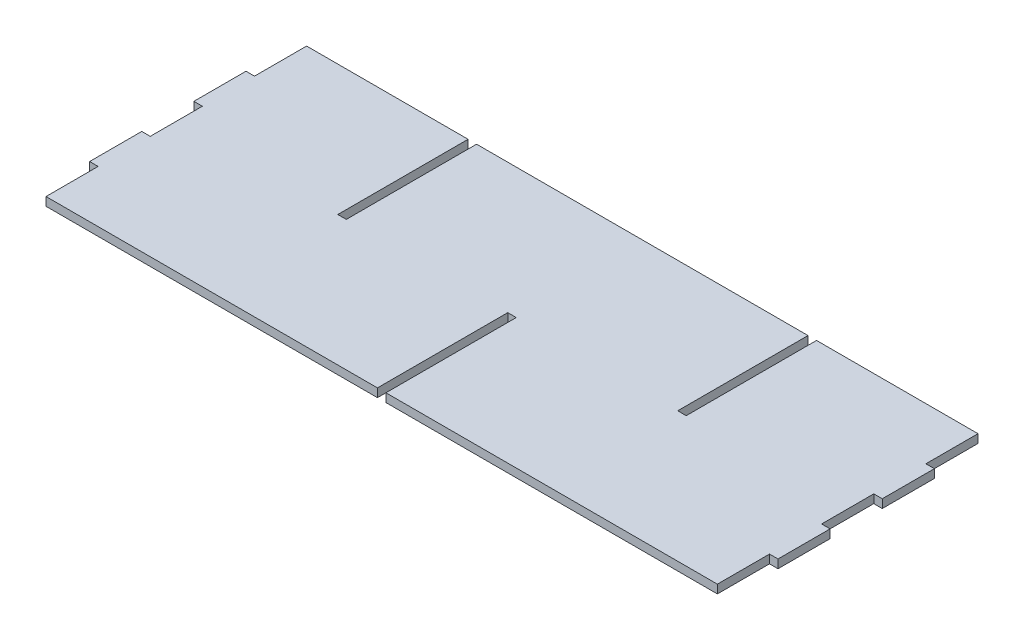
from build123d import *

# Parameters (mm, degrees)
ESTRUSIONE_ESTRUSIONE1_DEPTH = 1.5


with BuildPart() as part:
    # Schizzo4 → Estrusione-Estrusione1 (new body, symmetric)
    with BuildSketch(Plane(origin=(0, 0, 0), x_dir=(1, 0, 0), z_dir=(0, 1, 0))):
        Polygon((-61.5, 46), (-118.5, 46), (-118.5, 27.6), (-121.5, 27.6), (-121.5, 9.2), (-118.5, 9.2), (-118.5, -9.2), (-121.5, -9.2), (-121.5, -27.6), (-118.5, -27.6), (-118.5, -46), (-1.5, -46), (-1.5, 0), (1.5, 0), (1.5, -46), (118.5, -46), (118.5, -27.6), (121.5, -27.6), (121.5, -9.2), (118.5, -9.2), (118.5, 9.2), (121.5, 9.2), (121.5, 27.6), (118.5, 27.6), (118.5, 46), (61.5, 46), (61.5, 0), (58.5, 0), (58.5, 46), (-58.5, 46), (-58.5, 0), (-61.5, 0), align=None)
    extrude(amount=ESTRUSIONE_ESTRUSIONE1_DEPTH, both=True)


solid = part.part
